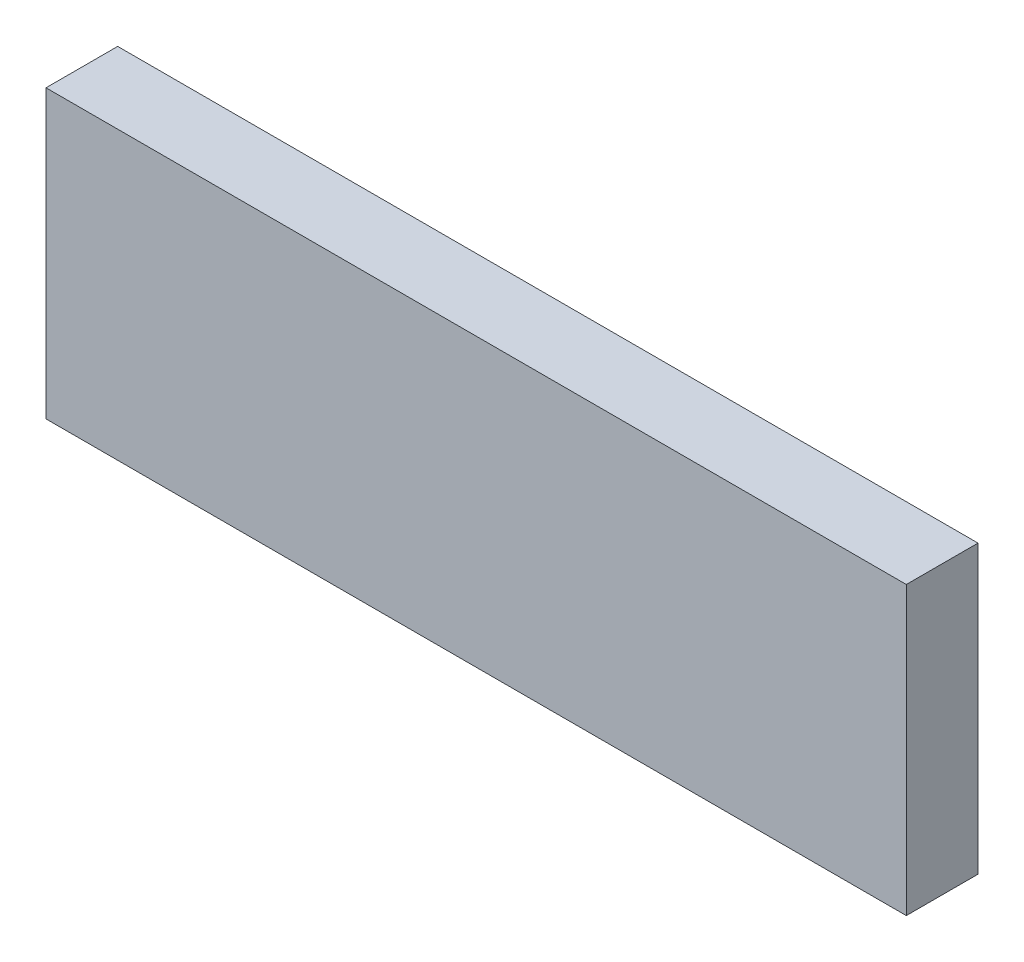
from build123d import *

# Parameters (mm, degrees)
SKETCH1_W           = 120
SKETCH1_H           = 40
BOSS_EXTRUDE1_DEPTH = 10


with BuildPart() as part:
    # Sketch1 → Boss-Extrude1 (new body)
    with BuildSketch(Plane.XY):
        Rectangle(SKETCH1_W, SKETCH1_H)
    extrude(amount=BOSS_EXTRUDE1_DEPTH)


solid = part.part
